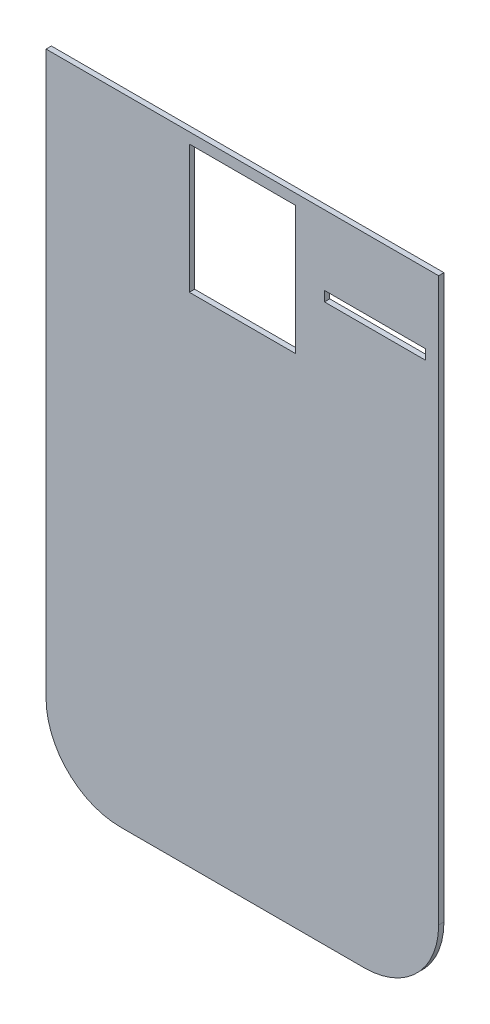
from build123d import *

# Parameters (mm, degrees)
BOSS_EXTRUDE1_DEPTH = 400
SKETCH2_W           = 100
SKETCH2_H           = 121
SKETCH2_W_2         = 95.3
SKETCH2_H_2         = 9.4
CUT_EXTRUDE1_DEPTH  = 268
CUT_EXTRUDE2_DEPTH  = 574
CUT_EXTRUDE3_DEPTH  = 574


with BuildPart() as part:
    # Sketch1 → Boss-Extrude1 (new body)
    with BuildSketch(Plane(origin=(0, 0, 0), x_dir=(0, 0, -1), z_dir=(1, 0, 0))):
        with BuildLine():
            Line((0, 0), (-350, 0))
            Line((-350, 0), (-350, 860))
            ThreePointArc((-350, 860), (-338.284271247, 888.284271247), (-310, 900))
            Line((-310, 900), (-158.48888922, 900))
            Line((-158.48888922, 900), (-158.48888922, 1060.696902422))
            ThreePointArc((-158.48888922, 1060.696902422), (-46.288149621, 1012.851918963), (0, 900))
            Line((0, 900), (0, 0))
        make_face()
    extrude(amount=BOSS_EXTRUDE1_DEPTH)

    # Sketch2 → Cut-Extrude1 (cut)
    with BuildSketch(Plane.XY.offset(350)):
        with Locations((200, 789.5)):
            Rectangle(SKETCH2_W, SKETCH2_H)
        with Locations((325, 789.5)):
            Rectangle(SKETCH2_W_2, SKETCH2_H_2)
    extrude(amount=-CUT_EXTRUDE1_DEPTH, mode=Mode.SUBTRACT)

    # Sketch3 → Cut-Extrude2 (cut)
    with BuildSketch(Plane.ZY):
        Polygon((350, 860), (345, 860), (345, -140.268205657), (-654.048621222, 0), (-155.382910131, 1729.32315512), (878.315397885, 1431.24705506), align=None)
    extrude(amount=-CUT_EXTRUDE2_DEPTH, mode=Mode.SUBTRACT)

    # Sketch4 → Cut-Extrude3 (cut)
    with BuildSketch(Plane.XY.offset(350)):
        with BuildLine():
            Line((15, 917.971493868), (15, 330))
            ThreePointArc((15, 330), (35.502525317, 280.502525317), (85, 260))
            Line((85, 260), (315, 260))
            ThreePointArc((315, 260), (364.497474683, 280.502525317), (385, 330))
            Line((385, 330), (385, 917.971493868))
            Line((385, 917.971493868), (580.540592228, 679.226510724))
            Line((580.540592228, 679.226510724), (899.548672457, -163.886240254))
            Line((899.548672457, -163.886240254), (163.483674451, -163.886240254))
            Line((163.483674451, -163.886240254), (110.907603164, -163.886240254))
            Line((110.907603164, -163.886240254), (-601.64880395, 753.812426605))
            Line((-601.64880395, 753.812426605), (15, 917.971493868))
        make_face()
    extrude(amount=-CUT_EXTRUDE3_DEPTH, mode=Mode.SUBTRACT)


solid = part.part
